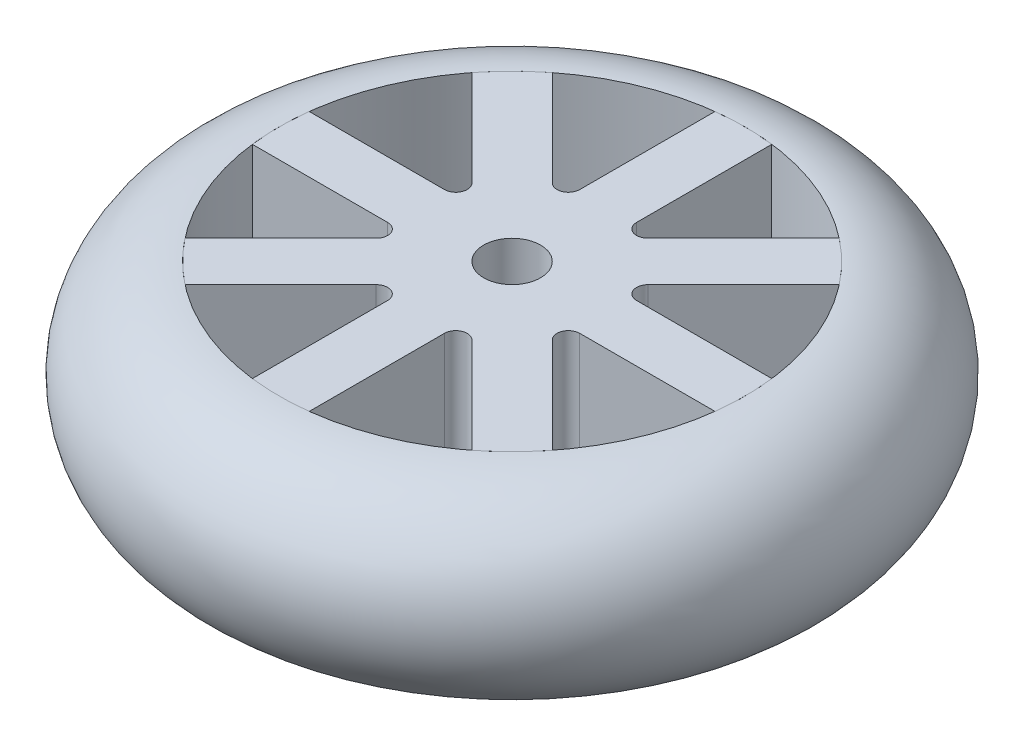
from build123d import *

# Parameters (mm, degrees)
SKETCH2_R           = 7
SKETCH2_R_2         = 2.5
BOSS_EXTRUDE1_DEPTH = 17
BOSS_EXTRUDE2_DEPTH = 17
SKETCH4_R           = 2.5
CUT_EXTRUDE1_DEPTH  = 17


with BuildPart() as part:
    # Sketch1 → Revolve1 (revolve)
    with BuildSketch(Plane.XY):
        with BuildLine():
            Line((-20.5, 0), (-20.5, 17))
            ThreePointArc((-20.5, 17), (-29, 8.5), (-20.5, 0))
        make_face()
    revolve(axis=Axis((0, -19.40997101, 0), (0, 1, 0)))


with BuildPart() as body_2:
    # Sketch2 → Boss-Extrude1 (new body)
    with BuildSketch(Plane(origin=(0, 0, 0), x_dir=(1, 0, 0), z_dir=(0, 1, 0))):
        Circle(SKETCH2_R)
        Circle(SKETCH2_R_2, mode=Mode.SUBTRACT)
    extrude(amount=BOSS_EXTRUDE1_DEPTH)

    # Sketch3 → Boss-Extrude2 (add)
    with BuildSketch(Plane(origin=(0, 0, 0), x_dir=(1, 0, 0), z_dir=(0, 1, 0))):
        with BuildLine():
            Line((-2.5, 20.346989949), (-2.5, 8.449747468))
            ThreePointArc((-2.5, 8.449747468), (-3.117316568, 7.525867936), (-4.207106781, 7.742640687))
            Line((-4.207106781, 7.742640687), (-12.619727617, 16.155261523))
            add(Edge.make_bspline(
                [(-16.155261523, 12.619727617), (-14.603883459, 14.603883459), (-12.619727617, 16.155261523)],
                knots=[0, 0, 0, 1, 1, 1], degree=2))
            Line((-16.155261523, 12.619727617), (-7.742640687, 4.207106781))
            ThreePointArc((-7.742640687, 4.207106781), (-7.525867936, 3.117316568), (-8.449747468, 2.5))
            Line((-8.449747468, 2.5), (-20.346989949, 2.5))
            add(Edge.make_bspline(
                [(-20.346989949, -2.5), (-20.653010051, 0), (-20.346989949, 2.5)],
                knots=[0, 0, 0, 1, 1, 1], degree=2))
            Line((-20.346989949, -2.5), (-8.449747468, -2.5))
            ThreePointArc((-8.449747468, -2.5), (-7.525867936, -3.117316568), (-7.742640687, -4.207106781))
            Line((-7.742640687, -4.207106781), (-16.155261523, -12.619727617))
            add(Edge.make_bspline(
                [(-16.155261523, -12.619727617), (-14.603883459, -14.603883459), (-12.619727617, -16.155261523)],
                knots=[0, 0, 0, 1, 1, 1], degree=2))
            Line((-12.619727617, -16.155261523), (-4.207106781, -7.742640687))
            ThreePointArc((-4.207106781, -7.742640687), (-3.117316568, -7.525867936), (-2.5, -8.449747468))
            Line((-2.5, -8.449747468), (-2.5, -20.346989949))
            add(Edge.make_bspline(
                [(-2.5, -20.346989949), (0, -20.653010051), (2.5, -20.346989949)],
                knots=[0, 0, 0, 1, 1, 1], degree=2))
            Line((2.5, -20.346989949), (2.5, -8.449747468))
            ThreePointArc((2.5, -8.449747468), (3.117316568, -7.525867936), (4.207106781, -7.742640687))
            Line((4.207106781, -7.742640687), (12.619727617, -16.155261523))
            add(Edge.make_bspline(
                [(12.619727617, -16.155261523), (14.603883459, -14.603883459), (16.155261523, -12.619727617)],
                knots=[0, 0, 0, 1, 1, 1], degree=2))
            Line((16.155261523, -12.619727617), (7.742640687, -4.207106781))
            ThreePointArc((7.742640687, -4.207106781), (7.525867936, -3.117316568), (8.449747468, -2.5))
            Line((8.449747468, -2.5), (20.346989949, -2.5))
            add(Edge.make_bspline(
                [(20.346989949, 2.5), (20.653010051, 0), (20.346989949, -2.5)],
                knots=[0, 0, 0, 1, 1, 1], degree=2))
            Line((20.346989949, 2.5), (8.449747468, 2.5))
            ThreePointArc((8.449747468, 2.5), (7.525867936, 3.117316568), (7.742640687, 4.207106781))
            Line((7.742640687, 4.207106781), (16.155261523, 12.619727617))
            add(Edge.make_bspline(
                [(12.619727617, 16.155261523), (14.603883459, 14.603883459), (16.155261523, 12.619727617)],
                knots=[0, 0, 0, 1, 1, 1], degree=2))
            Line((12.619727617, 16.155261523), (4.207106781, 7.742640687))
            ThreePointArc((4.207106781, 7.742640687), (3.117316568, 7.525867936), (2.5, 8.449747468))
            Line((2.5, 8.449747468), (2.5, 20.346989949))
            add(Edge.make_bspline(
                [(-2.5, 20.346989949), (0, 20.653010051), (2.5, 20.346989949)],
                knots=[0, 0, 0, 1, 1, 1], degree=2))
        make_face()
    extrude(amount=BOSS_EXTRUDE2_DEPTH)

    # Sketch4 → Cut-Extrude1 (cut)
    with BuildSketch(Plane(origin=(0, 17, 0), x_dir=(1, 0, 0), z_dir=(0, 1, 0))):
        Circle(SKETCH4_R)
    extrude(amount=-CUT_EXTRUDE1_DEPTH, mode=Mode.SUBTRACT)


solid = Compound([part.part, body_2.part])
